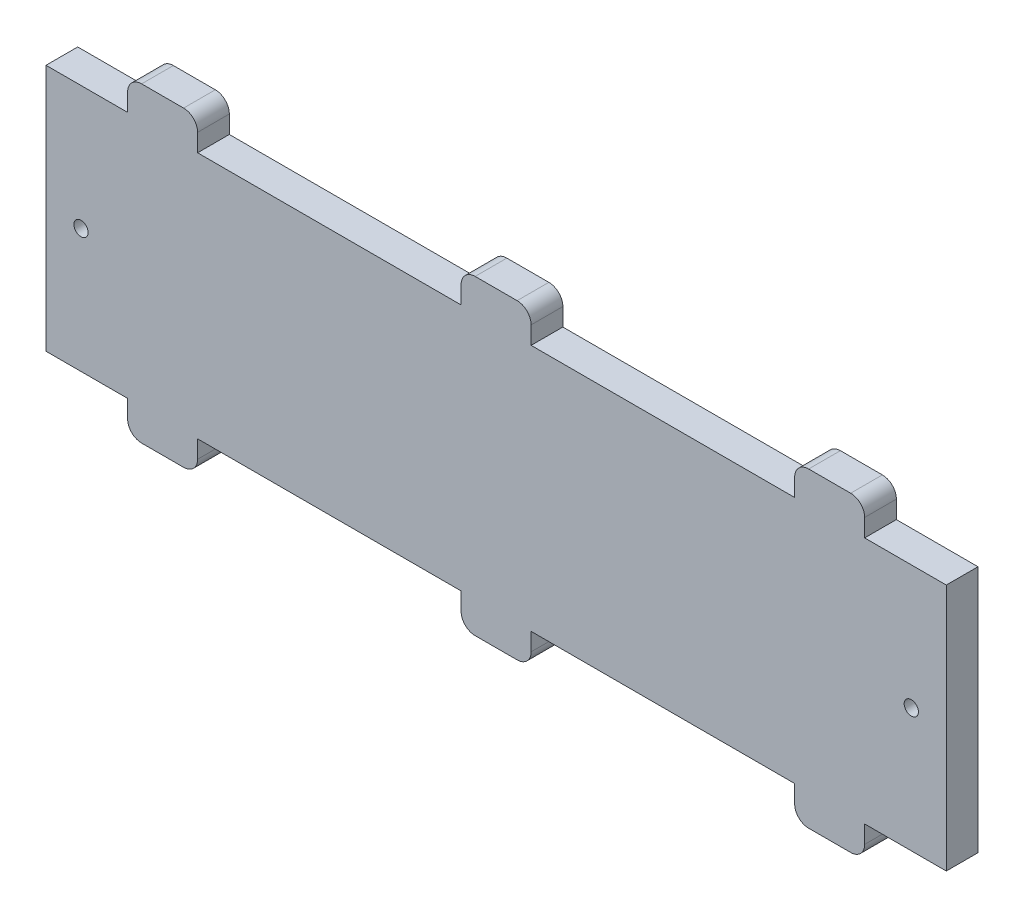
from build123d import *

# Parameters (mm, degrees)
SKETCH1_W            = 193
SKETCH1_H            = 53.1
BOSS_EXTRUDE1_DEPTH  = 6.8
SKETCH2_W            = 15
SKETCH2_H            = 6.8
BOSS_EXTRUDE2_DEPTH  = 6.8
SKETCH3_R            = 1.524
CUT_EXTRUDE1_DEPTH   = 6.8
FILLET1_R            = 3
FILLET1_OF_MIRROR1_R = 3


with BuildPart() as part:
    # Sketch1 → Boss-Extrude1 (new body)
    with BuildSketch(Plane.XY):
        Rectangle(SKETCH1_W, SKETCH1_H)
    extrude(amount=BOSS_EXTRUDE1_DEPTH)

    # Sketch2 → Boss-Extrude2 (add)
    with BuildSketch(Plane.XY.offset(6.8)):
        with Locations((0, 29.95)):
            Rectangle(SKETCH2_W, SKETCH2_H)
        with Locations((-71.5, 29.95)):
            Rectangle(SKETCH2_W, SKETCH2_H)
        with Locations((-71.5, -29.95)):
            Rectangle(SKETCH2_W, SKETCH2_H)
        with Locations((0, -29.95)):
            Rectangle(SKETCH2_W, SKETCH2_H)
    boss_extrude2 = extrude(amount=-BOSS_EXTRUDE2_DEPTH)

    # Sketch3 → Cut-Extrude1 (cut)
    with BuildSketch(Plane.XY.offset(6.8)):
        with Locations((-89, 0)):
            Circle(SKETCH3_R)
    cut_extrude1 = extrude(amount=-CUT_EXTRUDE1_DEPTH, mode=Mode.SUBTRACT)

    # Fillet1
    fillet1_edges = [part.edges().sort_by_distance(p)[0] for p in [
        (7.5, 33.35, 3.4),
        (-7.5, 33.35, 3.4),
        (-64, 33.35, 3.4),
        (-79, 33.35, 3.4),
        (7.5, -33.35, 3.4),
        (-7.5, -33.35, 3.4),
        (-64, -33.35, 3.4),
        (-79, -33.35, 3.4),
    ]]
    fillet(fillet1_edges, radius=FILLET1_R)

    # Mirror1: Boss-Extrude2, Cut-Extrude1 across plane
    add(boss_extrude2.mirror(Plane(origin=(0, 0, 0), x_dir=(0, 0, 1), z_dir=(1, 0, 0))))
    add(cut_extrude1.mirror(Plane(origin=(0, 0, 0), x_dir=(0, 0, 1), z_dir=(1, 0, 0))), mode=Mode.SUBTRACT)

    # Fillet1 of Mirror1
    fillet1_of_mirror1_edges = [part.edges().sort_by_distance(p)[0] for p in [
        (-7.5, 33.35, 3.4),
        (7.5, 33.35, 3.4),
        (64, 33.35, 3.4),
        (79, 33.35, 3.4),
        (-7.5, -33.35, 3.4),
        (7.5, -33.35, 3.4),
        (64, -33.35, 3.4),
        (79, -33.35, 3.4),
    ]]
    fillet(fillet1_of_mirror1_edges, radius=FILLET1_OF_MIRROR1_R)


solid = part.part
